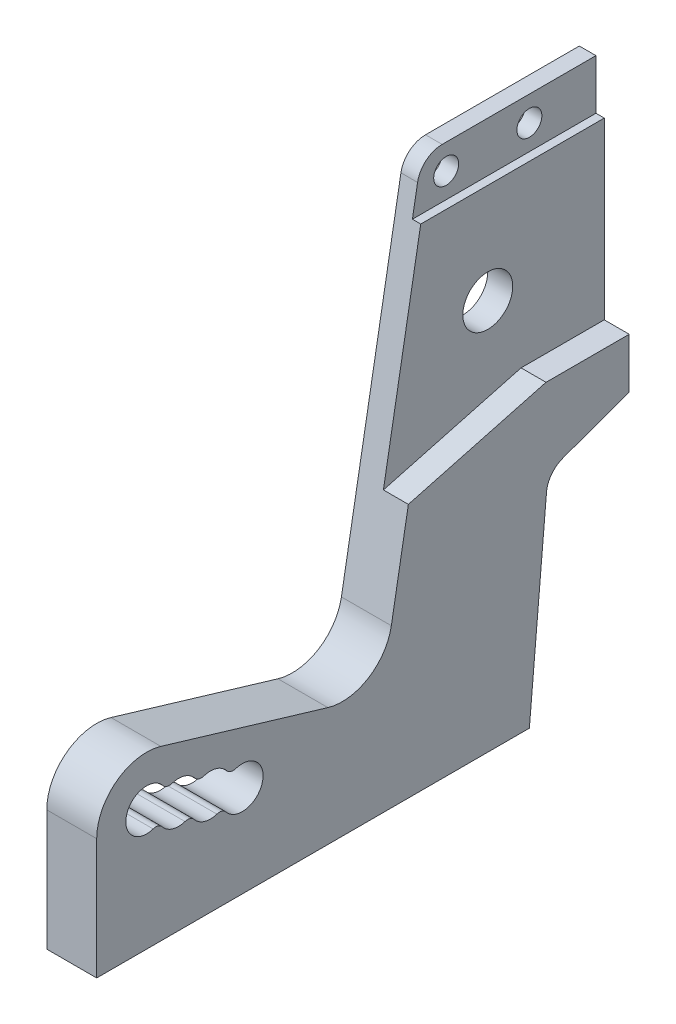
from build123d import *

# Parameters (mm, degrees)
SKETCH1_W                   = 64
SKETCH1_H                   = 62
SKETCH1_R                   = 2.5
SKETCH1_R_2                 = 3
BOSS_EXTRUDE1_DEPTH         = 6
CUT_EXTRUDE2_REACH          = 8
FILLET2_R                   = 3
TAP_DRILL_FOR_M3_TAP1_D     = 2.5
TAP_DRILL_FOR_M3_TAP1_DEPTH = 9
TAP_DRILL_FOR_M3_TAP1_TIP   = 0.751075774
CUT_EXTRUDE3_DEPTH          = 8
CUT_EXTRUDE4_DEPTH          = 3
FILLET3_R                   = 3
CUT_EXTRUDE5_REACH          = 5
SKETCH14_R                  = 1.5
SKETCH15_R                  = 2.5
CUT_EXTRUDE6_DEPTH          = 6
LPATTERN3_COUNT             = 3
LPATTERN3_PITCH             = 4
FILLET4_R                   = 1
SKETCH16_W                  = 22.057961884
SKETCH16_H                  = 6
CUT_EXTRUDE7_DEPTH          = 1


with BuildPart() as part:
    # Sketch1 → Boss-Extrude1 (new body)
    with BuildSketch(Plane(origin=(0, 0, 0), x_dir=(0, 0, -1), z_dir=(1, 0, 0))):
        with Locations((32, 31)):
            Rectangle(SKETCH1_W, SKETCH1_H)
        with Locations((6, 14.5)):
            Circle(SKETCH1_R, mode=Mode.SUBTRACT)
        with Locations((50, 44)):
            Circle(SKETCH1_R_2, mode=Mode.SUBTRACT)
    extrude(amount=BOSS_EXTRUDE1_DEPTH)

    # Sketch3 → Cut-Extrude2 (cut, up to next)
    with BuildSketch(Plane(origin=(6, 0, 0), x_dir=(0, 0, -1), z_dir=(1, 0, 0)), mode=Mode.PRIVATE) as cut_extrude2_sk1:
        Polygon((64, 0), (52, 0), (54.225932994, 25.442530542), (64, 29), align=None)
    cut_extrude2_tool1 = extrude(cut_extrude2_sk1.sketch, amount=-CUT_EXTRUDE2_REACH, mode=Mode.PRIVATE) & part.part
    add(cut_extrude2_tool1.solids().sort_by_distance((6, 13.1347, -58.667711))[0], mode=Mode.SUBTRACT)

    # Fillet2
    fillet2_edges = [part.edges().sort_by_distance(p)[0] for p in [
        (3, 25.442530542, -54.225932994),
    ]]
    fillet(fillet2_edges, radius=FILLET2_R)

    # Tap Drill for M3 Tap1
    with Locations(Plane(origin=(0, 0, 0), x_dir=(-1, 0, 0), z_dir=(0, -1, 0))):
        with Locations((-3, 48), (-3, 12)):
            Hole(TAP_DRILL_FOR_M3_TAP1_D / 2, depth=TAP_DRILL_FOR_M3_TAP1_DEPTH)
            with Locations((0, 0, -(TAP_DRILL_FOR_M3_TAP1_DEPTH + TAP_DRILL_FOR_M3_TAP1_TIP / 2))):  # 118° drill point
                Cone(0, TAP_DRILL_FOR_M3_TAP1_D / 2, TAP_DRILL_FOR_M3_TAP1_TIP, mode=Mode.SUBTRACT)

    # Sketch9 → Cut-Extrude3 (cut)
    with BuildSketch(Plane(origin=(6, 0, 0), x_dir=(0, 0, -1), z_dir=(1, 0, 0))):
        with BuildLine():
            Line((7.718264205, 20.248701429), (27.783442934, 14.251298571))
            ThreePointArc((27.783442934, 14.251298571), (32.652701535, 14.894000165), (35.410553657, 18.958110934))
            Line((35.410553657, 18.958110934), (43, 62))
            Line((43, 62), (0, 62))
            Line((0, 62), (0, 14.5))
            ThreePointArc((0, 14.5), (2.415978881, 19.311942707), (7.718264205, 20.248701429))
        make_face()
    extrude(amount=-CUT_EXTRUDE3_DEPTH, mode=Mode.SUBTRACT)

    # Sketch13 → Cut-Extrude4 (cut)
    with BuildSketch(Plane(origin=(6, 0, 0), x_dir=(0, 0, -1), z_dir=(1, 0, 0))):
        Polygon((54, 35), (64, 35), (64, 62), (43, 62), (37.457598082, 30.567476765), align=None)
    extrude(amount=-CUT_EXTRUDE4_DEPTH, mode=Mode.SUBTRACT)

    # Fillet3
    fillet3_edges = [part.edges().sort_by_distance(p)[0] for p in [
        (1.5, 62, -43),
    ]]
    fillet(fillet3_edges, radius=FILLET3_R)

    # Sketch14 → Cut-Extrude5 (cut, up to next)
    with BuildSketch(Plane(origin=(3, 0, 0), x_dir=(0, 0, -1), z_dir=(1, 0, 0)), mode=Mode.PRIVATE) as cut_extrude5_sk1:
        with Locations((56, 59)):
            Circle(SKETCH14_R)
    cut_extrude5_tool1 = extrude(cut_extrude5_sk1.sketch, amount=-CUT_EXTRUDE5_REACH, mode=Mode.PRIVATE) & part.part
    add(cut_extrude5_tool1.solids().sort_by_distance((3, 59, -56))[0], mode=Mode.SUBTRACT)
    # Sketch14 → Cut-Extrude5 (cut, up to next)
    with BuildSketch(Plane(origin=(3, 0, 0), x_dir=(0, 0, -1), z_dir=(1, 0, 0)), mode=Mode.PRIVATE) as cut_extrude5_sk2:
        with Locations((46, 59)):
            Circle(SKETCH14_R)
    cut_extrude5_tool2 = extrude(cut_extrude5_sk2.sketch, amount=-CUT_EXTRUDE5_REACH, mode=Mode.PRIVATE) & part.part
    add(cut_extrude5_tool2.solids().sort_by_distance((3, 59, -46))[0], mode=Mode.SUBTRACT)

    # Sketch15 → Cut-Extrude6 (cut)
    with BuildSketch(Plane.ZY):
        with Locations((-9.832467619, 13.35449053)):
            Circle(SKETCH15_R)
    cut_extrude6 = extrude(amount=-CUT_EXTRUDE6_DEPTH, mode=Mode.SUBTRACT)

    # LPattern3: Cut-Extrude6 ×3
    with Locations(*[Vector(0, -0.286377368, -0.958116905) * (i * LPATTERN3_PITCH) for i in range(1, LPATTERN3_COUNT)]):
        add(cut_extrude6, mode=Mode.SUBTRACT)

    # Fillet4
    fillet4_edges = [part.edges().sort_by_distance(p)[0] for p in [
        (3, 15.364420622, -8.345799861),
        (3, 12.490069908, -7.486667758),
        (3, 14.218911152, -12.17826748),
        (3, 11.344560437, -11.319135378),
        (3, 10.199050967, -15.151602997),
        (3, 13.073401682, -16.0107351),
    ]]
    fillet(fillet4_edges, radius=FILLET4_R)

    # Sketch16 → Cut-Extrude7 (cut)
    with BuildSketch(Plane(origin=(3, 0, 0), x_dir=(0, 0, -1), z_dir=(1, 0, 0))):
        with Locations((52.971019058, 59)):
            Rectangle(SKETCH16_W, SKETCH16_H)
    extrude(amount=-CUT_EXTRUDE7_DEPTH, mode=Mode.SUBTRACT)


solid = part.part
